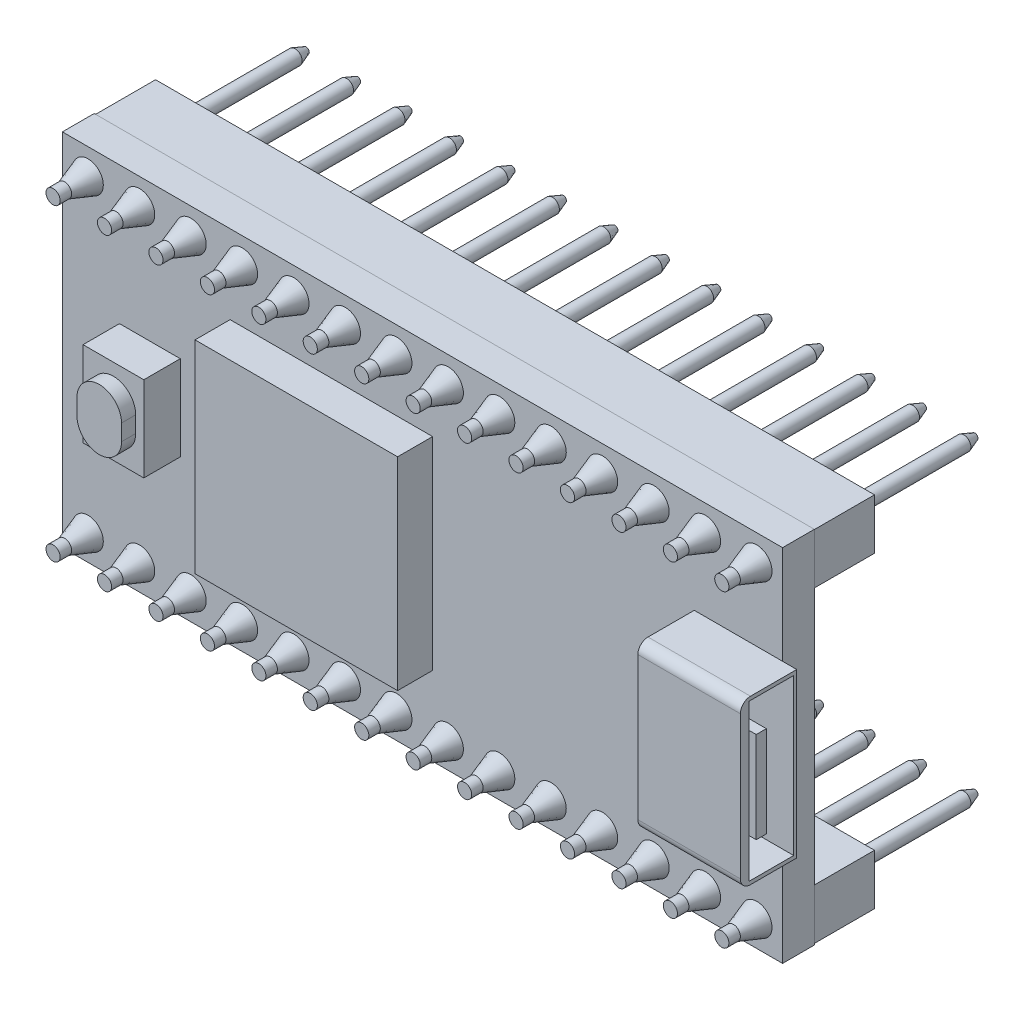
from build123d import *

# Parameters (mm, degrees)
SKIZZE1_W                            = 35.56
SKIZZE1_H                            = 17.78
AUFSATZ_LINEAR_AUSTRAGEN1_DEPTH      = 1.57
SKIZZE2_R                            = 0.35
AUFSATZ_LINEAR_AUSTRAGEN2_DEPTH      = 3.3
AUFSATZ_LINEAR_AUSTRAGEN2_DEPTH_BACK = 9.2
SKIZZE3_W                            = 5.06
SKIZZE3_H                            = 8.06
AUFSATZ_LINEAR_AUSTRAGEN3_DEPTH      = 2.785
SKIZZE4_W                            = 3
SKIZZE4_H                            = 4.2
AUFSATZ_LINEAR_AUSTRAGEN4_DEPTH      = 1.8
AUFSATZ_LINEAR_AUSTRAGEN5_DEPTH      = 0.7
SKIZZE6_W                            = 10
SKIZZE6_H                            = 10
AUFSATZ_LINEAR_AUSTRAGEN6_DEPTH      = 1.73
SKIZZE7_W                            = 2.2
SKIZZE7_H                            = 7.7
SKIZZE7_W_2                          = 0.5
SKIZZE7_H_2                          = 4.5
SCHNITT_LINEAR_AUSTRAGEN1_DEPTH      = 4.5
VERRUNDUNG1_R                        = 0.5
AUFSATZ_LINEAR_AUSTRAGEN8_DEPTH      = 3
SKIZZE9_R                            = 0.75
AUFSATZ_LINEAR_AUSTRAGEN9_DEPTH      = 1.7
AUFSATZ_LINEAR_AUSTRAGEN9_TAPER      = 19
FASE1_SIZE                           = 0.2
FASE1_SIZE2                          = 0.549495484
FASE1_PART_2_SIZE                    = 0.2
FASE1_PART_2_SIZE2                   = 0.549495484
FASE1_PART_3_SIZE                    = 0.2
FASE1_PART_3_SIZE2                   = 0.549495484
FASE1_PART_4_SIZE                    = 0.2
FASE1_PART_4_SIZE2                   = 0.549495484
FASE1_PART_5_SIZE                    = 0.2
FASE1_PART_5_SIZE2                   = 0.549495484
FASE1_PART_6_SIZE                    = 0.2
FASE1_PART_6_SIZE2                   = 0.549495484
FASE1_PART_7_SIZE                    = 0.2
FASE1_PART_7_SIZE2                   = 0.549495484
FASE1_PART_8_SIZE                    = 0.2
FASE1_PART_8_SIZE2                   = 0.549495484
FASE1_PART_9_SIZE                    = 0.2
FASE1_PART_9_SIZE2                   = 0.549495484
FASE1_PART_10_SIZE                   = 0.2
FASE1_PART_10_SIZE2                  = 0.549495484
FASE1_PART_11_SIZE                   = 0.2
FASE1_PART_11_SIZE2                  = 0.549495484
FASE1_PART_12_SIZE                   = 0.2
FASE1_PART_12_SIZE2                  = 0.549495484
FASE1_PART_13_SIZE                   = 0.2
FASE1_PART_13_SIZE2                  = 0.549495484
FASE1_PART_14_SIZE                   = 0.2
FASE1_PART_14_SIZE2                  = 0.549495484
FASE1_PART_15_SIZE                   = 0.2
FASE1_PART_15_SIZE2                  = 0.549495484
FASE1_PART_16_SIZE                   = 0.2
FASE1_PART_16_SIZE2                  = 0.549495484
FASE1_PART_17_SIZE                   = 0.2
FASE1_PART_17_SIZE2                  = 0.549495484
FASE1_PART_18_SIZE                   = 0.2
FASE1_PART_18_SIZE2                  = 0.549495484
FASE1_PART_19_SIZE                   = 0.2
FASE1_PART_19_SIZE2                  = 0.549495484
FASE1_PART_20_SIZE                   = 0.2
FASE1_PART_20_SIZE2                  = 0.549495484
FASE1_PART_21_SIZE                   = 0.2
FASE1_PART_21_SIZE2                  = 0.549495484
FASE1_PART_22_SIZE                   = 0.2
FASE1_PART_22_SIZE2                  = 0.549495484
FASE1_PART_23_SIZE                   = 0.2
FASE1_PART_23_SIZE2                  = 0.549495484
FASE1_PART_24_SIZE                   = 0.2
FASE1_PART_24_SIZE2                  = 0.549495484
FASE1_PART_25_SIZE                   = 0.2
FASE1_PART_25_SIZE2                  = 0.549495484
FASE1_PART_26_SIZE                   = 0.2
FASE1_PART_26_SIZE2                  = 0.549495484
FASE1_PART_27_SIZE                   = 0.2
FASE1_PART_27_SIZE2                  = 0.549495484
FASE1_PART_28_SIZE                   = 0.2
FASE1_PART_28_SIZE2                  = 0.549495484


with BuildPart() as part:
    # Skizze1 → Aufsatz-Linear austragen1 (new body)
    with BuildSketch(Plane.XY):
        Rectangle(SKIZZE1_W, SKIZZE1_H)
    extrude(amount=AUFSATZ_LINEAR_AUSTRAGEN1_DEPTH)

    # Skizze2 → Aufsatz-Linear austragen2 (add, two sides)
    with BuildSketch(Plane.XY) as aufsatz_linear_austragen2_sk:
        with Locations((-16.51, 7.62)):
            Circle(SKIZZE2_R)
        with Locations((-13.97, 7.62)):
            Circle(SKIZZE2_R)
        with Locations((-11.43, 7.62)):
            Circle(SKIZZE2_R)
        with Locations((-8.89, 7.62)):
            Circle(SKIZZE2_R)
        with Locations((-6.35, 7.62)):
            Circle(SKIZZE2_R)
        with Locations((-3.81, 7.62)):
            Circle(SKIZZE2_R)
        with Locations((-1.27, 7.62)):
            Circle(SKIZZE2_R)
        with Locations((1.27, 7.62)):
            Circle(SKIZZE2_R)
        with Locations((3.81, 7.62)):
            Circle(SKIZZE2_R)
        with Locations((6.35, 7.62)):
            Circle(SKIZZE2_R)
        with Locations((8.89, 7.62)):
            Circle(SKIZZE2_R)
        with Locations((11.43, 7.62)):
            Circle(SKIZZE2_R)
        with Locations((13.97, 7.62)):
            Circle(SKIZZE2_R)
        with Locations((16.51, 7.62)):
            Circle(SKIZZE2_R)
        with Locations((-16.51, -7.62)):
            Circle(SKIZZE2_R)
        with Locations((-13.97, -7.62)):
            Circle(SKIZZE2_R)
        with Locations((-11.43, -7.62)):
            Circle(SKIZZE2_R)
        with Locations((-8.89, -7.62)):
            Circle(SKIZZE2_R)
        with Locations((-6.35, -7.62)):
            Circle(SKIZZE2_R)
        with Locations((-3.81, -7.62)):
            Circle(SKIZZE2_R)
        with Locations((-1.27, -7.62)):
            Circle(SKIZZE2_R)
        with Locations((1.27, -7.62)):
            Circle(SKIZZE2_R)
        with Locations((3.81, -7.62)):
            Circle(SKIZZE2_R)
        with Locations((6.35, -7.62)):
            Circle(SKIZZE2_R)
        with Locations((8.89, -7.62)):
            Circle(SKIZZE2_R)
        with Locations((11.43, -7.62)):
            Circle(SKIZZE2_R)
        with Locations((13.97, -7.62)):
            Circle(SKIZZE2_R)
        with Locations((16.51, -7.62)):
            Circle(SKIZZE2_R)
    extrude(amount=AUFSATZ_LINEAR_AUSTRAGEN2_DEPTH)
    extrude(aufsatz_linear_austragen2_sk.sketch, amount=-AUFSATZ_LINEAR_AUSTRAGEN2_DEPTH_BACK)

    # Skizze3 → Aufsatz-Linear austragen3 (add)
    with BuildSketch(Plane.XY.offset(1.57)):
        with Locations((15.95, 0)):
            Rectangle(SKIZZE3_W, SKIZZE3_H)
    extrude(amount=AUFSATZ_LINEAR_AUSTRAGEN3_DEPTH)

    # Skizze4 → Aufsatz-Linear austragen4 (add)
    with BuildSketch(Plane.XY.offset(1.57)):
        with Locations((-13.46, 0)):
            Rectangle(SKIZZE4_W, SKIZZE4_H)
    extrude(amount=AUFSATZ_LINEAR_AUSTRAGEN4_DEPTH)

    # Skizze5 → Aufsatz-Linear austragen5 (add)
    with BuildSketch(Plane.XY.offset(3.37)):
        with BuildLine():
            Line((-14.56, -0.4), (-14.56, 0.4))
            ThreePointArc((-14.56, 0.4), (-13.46, 1.5), (-12.36, 0.4))
            Line((-12.36, 0.4), (-12.36, -0.4))
            ThreePointArc((-12.36, -0.4), (-13.46, -1.5), (-14.56, -0.4))
        make_face()
    extrude(amount=AUFSATZ_LINEAR_AUSTRAGEN5_DEPTH)

    # Skizze6 → Aufsatz-Linear austragen6 (add)
    with BuildSketch(Plane.XY.offset(1.57)):
        with Locations((-4.5, 0)):
            Rectangle(SKIZZE6_W, SKIZZE6_H)
    extrude(amount=AUFSATZ_LINEAR_AUSTRAGEN6_DEPTH)

    # Skizze7 → Schnitt-Linear austragen1 (cut)
    with BuildSketch(Plane(origin=(18.48, 0, 0), x_dir=(0, 0, -1), z_dir=(1, 0, 0))):
        with Locations((-2.82, 0)):
            Rectangle(SKIZZE7_W, SKIZZE7_H)
        with Locations((-3.32, 0)):
            Rectangle(SKIZZE7_W_2, SKIZZE7_H_2, mode=Mode.SUBTRACT)
    extrude(amount=-SCHNITT_LINEAR_AUSTRAGEN1_DEPTH, mode=Mode.SUBTRACT)

    # Verrundung1
    verrundung1_edges = [part.edges().sort_by_distance(p)[0] for p in [
        (15.95, 4.03, 4.355),
        (15.95, -4.03, 4.355),
    ]]
    fillet(verrundung1_edges, radius=VERRUNDUNG1_R)

    # Skizze8 → Aufsatz-Linear austragen8 (add)
    with BuildSketch(Plane.XY):
        Polygon((-17.75, -8.85), (17.75, -8.85), (17.75, -6.35), (-15.21, -6.35), (-17.75, -6.35), align=None)
        Polygon((-17.75, 8.85), (17.75, 8.85), (17.75, 6.35), (-15.21, 6.35), (-17.75, 6.35), align=None)
    extrude(amount=-AUFSATZ_LINEAR_AUSTRAGEN8_DEPTH)

    # Skizze9 → Aufsatz-Linear austragen9 (add)
    with BuildSketch(Plane.XY.offset(1.57)):
        with Locations((-16.51, 7.62)):
            Circle(SKIZZE9_R)
        with Locations((-13.97, 7.62)):
            Circle(SKIZZE9_R)
        with Locations((-11.43, 7.62)):
            Circle(SKIZZE9_R)
        with Locations((-8.89, 7.62)):
            Circle(SKIZZE9_R)
        with Locations((-6.35, 7.62)):
            Circle(SKIZZE9_R)
        with Locations((-3.81, 7.62)):
            Circle(SKIZZE9_R)
        with Locations((-1.27, 7.62)):
            Circle(SKIZZE9_R)
        with Locations((1.27, 7.62)):
            Circle(SKIZZE9_R)
        with Locations((3.81, 7.62)):
            Circle(SKIZZE9_R)
        with Locations((6.35, 7.62)):
            Circle(SKIZZE9_R)
        with Locations((8.89, 7.62)):
            Circle(SKIZZE9_R)
        with Locations((11.43, 7.62)):
            Circle(SKIZZE9_R)
        with Locations((13.97, 7.62)):
            Circle(SKIZZE9_R)
        with Locations((16.51, 7.62)):
            Circle(SKIZZE9_R)
        with Locations((-16.51, -7.62)):
            Circle(SKIZZE9_R)
        with Locations((-13.97, -7.62)):
            Circle(SKIZZE9_R)
        with Locations((-11.43, -7.62)):
            Circle(SKIZZE9_R)
        with Locations((-8.89, -7.62)):
            Circle(SKIZZE9_R)
        with Locations((-6.35, -7.62)):
            Circle(SKIZZE9_R)
        with Locations((-3.81, -7.62)):
            Circle(SKIZZE9_R)
        with Locations((-1.27, -7.62)):
            Circle(SKIZZE9_R)
        with Locations((1.27, -7.62)):
            Circle(SKIZZE9_R)
        with Locations((3.81, -7.62)):
            Circle(SKIZZE9_R)
        with Locations((6.35, -7.62)):
            Circle(SKIZZE9_R)
        with Locations((8.89, -7.62)):
            Circle(SKIZZE9_R)
        with Locations((11.43, -7.62)):
            Circle(SKIZZE9_R)
        with Locations((13.97, -7.62)):
            Circle(SKIZZE9_R)
        with Locations((16.51, -7.62)):
            Circle(SKIZZE9_R)
    extrude(amount=AUFSATZ_LINEAR_AUSTRAGEN9_DEPTH, taper=AUFSATZ_LINEAR_AUSTRAGEN9_TAPER)

    # Fase1
    fase1_edges = [part.edges().sort_by_distance(p)[0] for p in [
        (-11.78, -7.62, -9.2),
    ]]
    fase1_side = [part.faces().sort_by_distance(p)[0] for p in [
        (-11.43, -7.62, -9.2),
    ]]
    chamfer(fase1_edges, length=FASE1_SIZE, length2=FASE1_SIZE2, reference=fase1_side[0])

    # Fase1 part 2
    fase1_part_2_edges = [part.edges().sort_by_distance(p)[0] for p in [
        (-9.24, -7.62, -9.2),
    ]]
    fase1_part_2_side = [part.faces().sort_by_distance(p)[0] for p in [
        (-8.89, -7.62, -9.2),
    ]]
    chamfer(fase1_part_2_edges, length=FASE1_PART_2_SIZE, length2=FASE1_PART_2_SIZE2, reference=fase1_part_2_side[0])

    # Fase1 part 3
    fase1_part_3_edges = [part.edges().sort_by_distance(p)[0] for p in [
        (-6.7, -7.62, -9.2),
    ]]
    fase1_part_3_side = [part.faces().sort_by_distance(p)[0] for p in [
        (-6.35, -7.62, -9.2),
    ]]
    chamfer(fase1_part_3_edges, length=FASE1_PART_3_SIZE, length2=FASE1_PART_3_SIZE2, reference=fase1_part_3_side[0])

    # Fase1 part 4
    fase1_part_4_edges = [part.edges().sort_by_distance(p)[0] for p in [
        (-4.16, -7.62, -9.2),
    ]]
    fase1_part_4_side = [part.faces().sort_by_distance(p)[0] for p in [
        (-3.81, -7.62, -9.2),
    ]]
    chamfer(fase1_part_4_edges, length=FASE1_PART_4_SIZE, length2=FASE1_PART_4_SIZE2, reference=fase1_part_4_side[0])

    # Fase1 part 5
    fase1_part_5_edges = [part.edges().sort_by_distance(p)[0] for p in [
        (-1.62, -7.62, -9.2),
    ]]
    fase1_part_5_side = [part.faces().sort_by_distance(p)[0] for p in [
        (-1.27, -7.62, -9.2),
    ]]
    chamfer(fase1_part_5_edges, length=FASE1_PART_5_SIZE, length2=FASE1_PART_5_SIZE2, reference=fase1_part_5_side[0])

    # Fase1 part 6
    fase1_part_6_edges = [part.edges().sort_by_distance(p)[0] for p in [
        (0.92, -7.62, -9.2),
    ]]
    fase1_part_6_side = [part.faces().sort_by_distance(p)[0] for p in [
        (1.27, -7.62, -9.2),
    ]]
    chamfer(fase1_part_6_edges, length=FASE1_PART_6_SIZE, length2=FASE1_PART_6_SIZE2, reference=fase1_part_6_side[0])

    # Fase1 part 7
    fase1_part_7_edges = [part.edges().sort_by_distance(p)[0] for p in [
        (3.46, -7.62, -9.2),
    ]]
    fase1_part_7_side = [part.faces().sort_by_distance(p)[0] for p in [
        (3.81, -7.62, -9.2),
    ]]
    chamfer(fase1_part_7_edges, length=FASE1_PART_7_SIZE, length2=FASE1_PART_7_SIZE2, reference=fase1_part_7_side[0])

    # Fase1 part 8
    fase1_part_8_edges = [part.edges().sort_by_distance(p)[0] for p in [
        (6, -7.62, -9.2),
    ]]
    fase1_part_8_side = [part.faces().sort_by_distance(p)[0] for p in [
        (6.35, -7.62, -9.2),
    ]]
    chamfer(fase1_part_8_edges, length=FASE1_PART_8_SIZE, length2=FASE1_PART_8_SIZE2, reference=fase1_part_8_side[0])

    # Fase1 part 9
    fase1_part_9_edges = [part.edges().sort_by_distance(p)[0] for p in [
        (8.54, -7.62, -9.2),
    ]]
    fase1_part_9_side = [part.faces().sort_by_distance(p)[0] for p in [
        (8.89, -7.62, -9.2),
    ]]
    chamfer(fase1_part_9_edges, length=FASE1_PART_9_SIZE, length2=FASE1_PART_9_SIZE2, reference=fase1_part_9_side[0])

    # Fase1 part 10
    fase1_part_10_edges = [part.edges().sort_by_distance(p)[0] for p in [
        (11.08, -7.62, -9.2),
    ]]
    fase1_part_10_side = [part.faces().sort_by_distance(p)[0] for p in [
        (11.43, -7.62, -9.2),
    ]]
    chamfer(fase1_part_10_edges, length=FASE1_PART_10_SIZE, length2=FASE1_PART_10_SIZE2, reference=fase1_part_10_side[0])

    # Fase1 part 11
    fase1_part_11_edges = [part.edges().sort_by_distance(p)[0] for p in [
        (-16.86, 7.62, -9.2),
    ]]
    fase1_part_11_side = [part.faces().sort_by_distance(p)[0] for p in [
        (-16.51, 7.62, -9.2),
    ]]
    chamfer(fase1_part_11_edges, length=FASE1_PART_11_SIZE, length2=FASE1_PART_11_SIZE2, reference=fase1_part_11_side[0])

    # Fase1 part 12
    fase1_part_12_edges = [part.edges().sort_by_distance(p)[0] for p in [
        (13.62, -7.62, -9.2),
    ]]
    fase1_part_12_side = [part.faces().sort_by_distance(p)[0] for p in [
        (13.97, -7.62, -9.2),
    ]]
    chamfer(fase1_part_12_edges, length=FASE1_PART_12_SIZE, length2=FASE1_PART_12_SIZE2, reference=fase1_part_12_side[0])

    # Fase1 part 13
    fase1_part_13_edges = [part.edges().sort_by_distance(p)[0] for p in [
        (16.16, -7.62, -9.2),
    ]]
    fase1_part_13_side = [part.faces().sort_by_distance(p)[0] for p in [
        (16.51, -7.62, -9.2),
    ]]
    chamfer(fase1_part_13_edges, length=FASE1_PART_13_SIZE, length2=FASE1_PART_13_SIZE2, reference=fase1_part_13_side[0])

    # Fase1 part 14
    fase1_part_14_edges = [part.edges().sort_by_distance(p)[0] for p in [
        (-14.32, 7.62, -9.2),
    ]]
    fase1_part_14_side = [part.faces().sort_by_distance(p)[0] for p in [
        (-13.97, 7.62, -9.2),
    ]]
    chamfer(fase1_part_14_edges, length=FASE1_PART_14_SIZE, length2=FASE1_PART_14_SIZE2, reference=fase1_part_14_side[0])

    # Fase1 part 15
    fase1_part_15_edges = [part.edges().sort_by_distance(p)[0] for p in [
        (-11.78, 7.62, -9.2),
    ]]
    fase1_part_15_side = [part.faces().sort_by_distance(p)[0] for p in [
        (-11.43, 7.62, -9.2),
    ]]
    chamfer(fase1_part_15_edges, length=FASE1_PART_15_SIZE, length2=FASE1_PART_15_SIZE2, reference=fase1_part_15_side[0])

    # Fase1 part 16
    fase1_part_16_edges = [part.edges().sort_by_distance(p)[0] for p in [
        (-9.24, 7.62, -9.2),
    ]]
    fase1_part_16_side = [part.faces().sort_by_distance(p)[0] for p in [
        (-8.89, 7.62, -9.2),
    ]]
    chamfer(fase1_part_16_edges, length=FASE1_PART_16_SIZE, length2=FASE1_PART_16_SIZE2, reference=fase1_part_16_side[0])

    # Fase1 part 17
    fase1_part_17_edges = [part.edges().sort_by_distance(p)[0] for p in [
        (-6.7, 7.62, -9.2),
    ]]
    fase1_part_17_side = [part.faces().sort_by_distance(p)[0] for p in [
        (-6.35, 7.62, -9.2),
    ]]
    chamfer(fase1_part_17_edges, length=FASE1_PART_17_SIZE, length2=FASE1_PART_17_SIZE2, reference=fase1_part_17_side[0])

    # Fase1 part 18
    fase1_part_18_edges = [part.edges().sort_by_distance(p)[0] for p in [
        (-4.16, 7.62, -9.2),
    ]]
    fase1_part_18_side = [part.faces().sort_by_distance(p)[0] for p in [
        (-3.81, 7.62, -9.2),
    ]]
    chamfer(fase1_part_18_edges, length=FASE1_PART_18_SIZE, length2=FASE1_PART_18_SIZE2, reference=fase1_part_18_side[0])

    # Fase1 part 19
    fase1_part_19_edges = [part.edges().sort_by_distance(p)[0] for p in [
        (-1.62, 7.62, -9.2),
    ]]
    fase1_part_19_side = [part.faces().sort_by_distance(p)[0] for p in [
        (-1.27, 7.62, -9.2),
    ]]
    chamfer(fase1_part_19_edges, length=FASE1_PART_19_SIZE, length2=FASE1_PART_19_SIZE2, reference=fase1_part_19_side[0])

    # Fase1 part 20
    fase1_part_20_edges = [part.edges().sort_by_distance(p)[0] for p in [
        (0.92, 7.62, -9.2),
    ]]
    fase1_part_20_side = [part.faces().sort_by_distance(p)[0] for p in [
        (1.27, 7.62, -9.2),
    ]]
    chamfer(fase1_part_20_edges, length=FASE1_PART_20_SIZE, length2=FASE1_PART_20_SIZE2, reference=fase1_part_20_side[0])

    # Fase1 part 21
    fase1_part_21_edges = [part.edges().sort_by_distance(p)[0] for p in [
        (3.46, 7.62, -9.2),
    ]]
    fase1_part_21_side = [part.faces().sort_by_distance(p)[0] for p in [
        (3.81, 7.62, -9.2),
    ]]
    chamfer(fase1_part_21_edges, length=FASE1_PART_21_SIZE, length2=FASE1_PART_21_SIZE2, reference=fase1_part_21_side[0])

    # Fase1 part 22
    fase1_part_22_edges = [part.edges().sort_by_distance(p)[0] for p in [
        (6, 7.62, -9.2),
    ]]
    fase1_part_22_side = [part.faces().sort_by_distance(p)[0] for p in [
        (6.35, 7.62, -9.2),
    ]]
    chamfer(fase1_part_22_edges, length=FASE1_PART_22_SIZE, length2=FASE1_PART_22_SIZE2, reference=fase1_part_22_side[0])

    # Fase1 part 23
    fase1_part_23_edges = [part.edges().sort_by_distance(p)[0] for p in [
        (8.54, 7.62, -9.2),
    ]]
    fase1_part_23_side = [part.faces().sort_by_distance(p)[0] for p in [
        (8.89, 7.62, -9.2),
    ]]
    chamfer(fase1_part_23_edges, length=FASE1_PART_23_SIZE, length2=FASE1_PART_23_SIZE2, reference=fase1_part_23_side[0])

    # Fase1 part 24
    fase1_part_24_edges = [part.edges().sort_by_distance(p)[0] for p in [
        (11.08, 7.62, -9.2),
    ]]
    fase1_part_24_side = [part.faces().sort_by_distance(p)[0] for p in [
        (11.43, 7.62, -9.2),
    ]]
    chamfer(fase1_part_24_edges, length=FASE1_PART_24_SIZE, length2=FASE1_PART_24_SIZE2, reference=fase1_part_24_side[0])

    # Fase1 part 25
    fase1_part_25_edges = [part.edges().sort_by_distance(p)[0] for p in [
        (13.62, 7.62, -9.2),
    ]]
    fase1_part_25_side = [part.faces().sort_by_distance(p)[0] for p in [
        (13.97, 7.62, -9.2),
    ]]
    chamfer(fase1_part_25_edges, length=FASE1_PART_25_SIZE, length2=FASE1_PART_25_SIZE2, reference=fase1_part_25_side[0])

    # Fase1 part 26
    fase1_part_26_edges = [part.edges().sort_by_distance(p)[0] for p in [
        (16.16, 7.62, -9.2),
    ]]
    fase1_part_26_side = [part.faces().sort_by_distance(p)[0] for p in [
        (16.51, 7.62, -9.2),
    ]]
    chamfer(fase1_part_26_edges, length=FASE1_PART_26_SIZE, length2=FASE1_PART_26_SIZE2, reference=fase1_part_26_side[0])

    # Fase1 part 27
    fase1_part_27_edges = [part.edges().sort_by_distance(p)[0] for p in [
        (-16.86, -7.62, -9.2),
    ]]
    fase1_part_27_side = [part.faces().sort_by_distance(p)[0] for p in [
        (-16.51, -7.62, -9.2),
    ]]
    chamfer(fase1_part_27_edges, length=FASE1_PART_27_SIZE, length2=FASE1_PART_27_SIZE2, reference=fase1_part_27_side[0])

    # Fase1 part 28
    fase1_part_28_edges = [part.edges().sort_by_distance(p)[0] for p in [
        (-14.32, -7.62, -9.2),
    ]]
    fase1_part_28_side = [part.faces().sort_by_distance(p)[0] for p in [
        (-13.97, -7.62, -9.2),
    ]]
    chamfer(fase1_part_28_edges, length=FASE1_PART_28_SIZE, length2=FASE1_PART_28_SIZE2, reference=fase1_part_28_side[0])


solid = part.part
